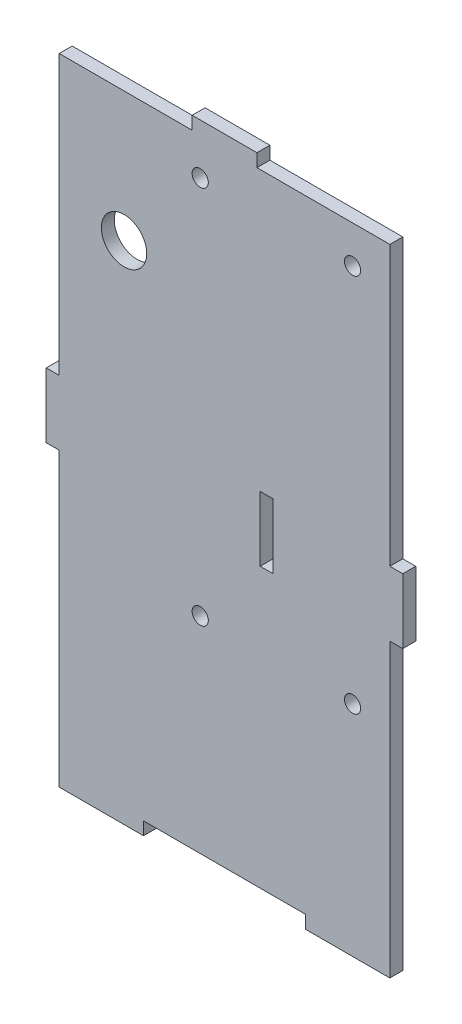
from build123d import *

# Parameters (mm, degrees)
SKETCH1_R           = 1.25
SKETCH1_R_2         = 3.5
SKETCH1_W           = 2
SKETCH1_H           = 10
BOSS_EXTRUDE1_DEPTH = 2


with BuildPart() as part:
    # Sketch1 → Boss-Extrude1 (new body)
    with BuildSketch(Plane.XY):
        Polygon((22.5, 100), (22.5, 98), (2, 98), (2, 55), (0, 55), (0, 45), (2, 45), (2, 0), (15, 0), (15, 2), (40, 2), (40, 0), (53, 0), (53, 45), (55, 45), (55, 55), (53, 55), (53, 98), (32.5, 98), (32.5, 100), align=None)
        with Locations((47.25, 92.25)):
            Circle(SKETCH1_R, mode=Mode.SUBTRACT)
        with Locations((23.75, 92.25)):
            Circle(SKETCH1_R, mode=Mode.SUBTRACT)
        with Locations((47.25, 33.75)):
            Circle(SKETCH1_R, mode=Mode.SUBTRACT)
        with Locations((23.75, 33.75)):
            Circle(SKETCH1_R, mode=Mode.SUBTRACT)
        with Locations((12, 78)):
            Circle(SKETCH1_R_2, mode=Mode.SUBTRACT)
        with Locations((34, 50)):
            Rectangle(SKETCH1_W, SKETCH1_H, mode=Mode.SUBTRACT)
    extrude(amount=BOSS_EXTRUDE1_DEPTH)


solid = part.part
